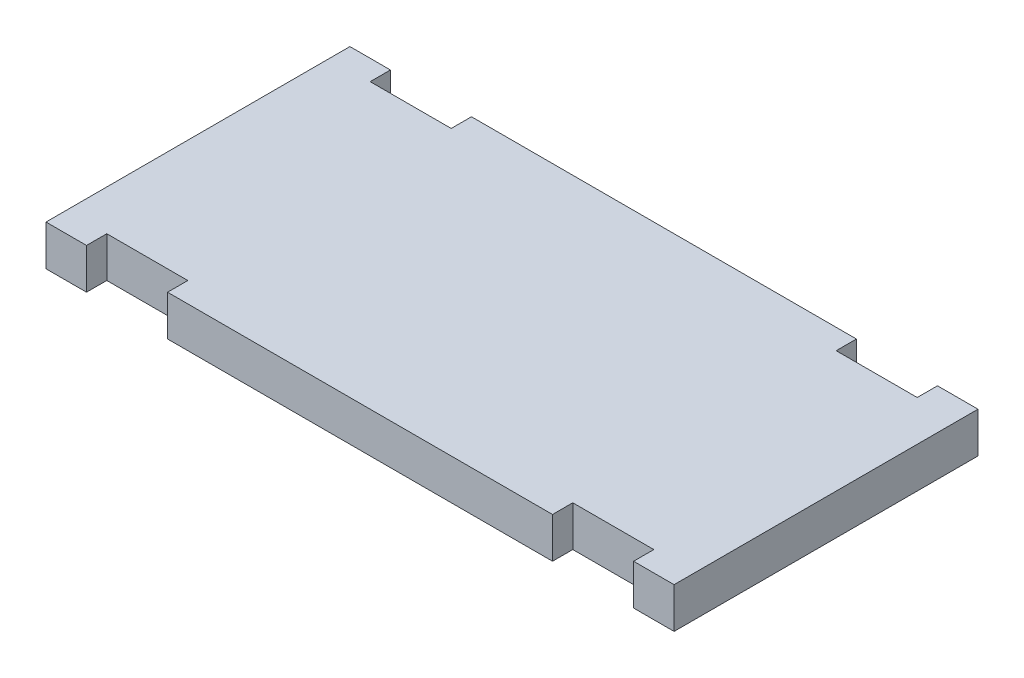
from build123d import *

# Parameters (mm, degrees)
BOSS_EXTRUDE1_DEPTH = 1


with BuildPart() as part:
    # Sketch1 → Boss-Extrude1 (new body)
    with BuildSketch(Plane(origin=(0, 0, 0), x_dir=(1, 0, 0), z_dir=(0, 1, 0))):
        Polygon((-7.75, 3.75), (-6.75, 3.75), (-6.75, 3.25), (-4.75, 3.25), (-4.75, 3.75), (4.75, 3.75), (4.75, 3.25), (6.75, 3.25), (6.75, 3.75), (7.75, 3.75), (7.75, -3.75), (6.75, -3.75), (6.75, -3.25), (4.75, -3.25), (4.75, -3.75), (-4.75, -3.75), (-4.75, -3.25), (-6.75, -3.25), (-6.75, -3.75), (-7.75, -3.75), align=None)
    extrude(amount=BOSS_EXTRUDE1_DEPTH)


solid = part.part
